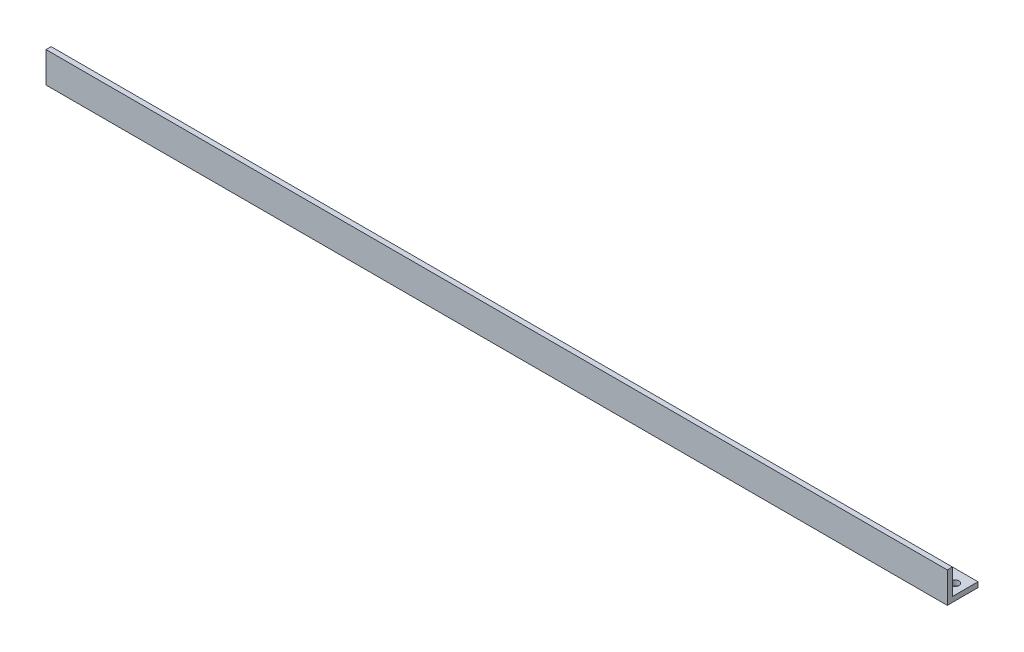
from build123d import *

# Parameters (mm, degrees)
BOSS_EXTRUDE1_DEPTH = 558.8
CUT_EXTRUDE1_REACH  = 5.175
SKETCH2_R           = 2.54


with BuildPart() as part:
    # Sketch1 → Boss-Extrude1 (new body)
    with BuildSketch(Plane(origin=(0, 0, 0), x_dir=(0, 0, -1), z_dir=(1, 0, 0))):
        Polygon((3.175, 3.175), (3.175, 19.05), (0, 19.05), (0, 0), (19.05, 0), (19.05, 3.175), align=None)
    extrude(amount=BOSS_EXTRUDE1_DEPTH)

    # Sketch2 → Cut-Extrude1 (cut, up to next)
    with BuildSketch(Plane(origin=(0, 3.175, 0), x_dir=(1, 0, 0), z_dir=(0, 1, 0)), mode=Mode.PRIVATE) as cut_extrude1_sk1:
        with Locations((552.45, 11.1125)):
            Circle(SKETCH2_R)
    cut_extrude1_tool1 = extrude(cut_extrude1_sk1.sketch, amount=-CUT_EXTRUDE1_REACH, mode=Mode.PRIVATE) & part.part
    add(cut_extrude1_tool1.solids().sort_by_distance((552.45, 3.175, -11.1125))[0], mode=Mode.SUBTRACT)
    # Sketch2 → Cut-Extrude1 (cut, up to next)
    with BuildSketch(Plane(origin=(0, 3.175, 0), x_dir=(1, 0, 0), z_dir=(0, 1, 0)), mode=Mode.PRIVATE) as cut_extrude1_sk2:
        with Locations((6.35, 11.1125)):
            Circle(SKETCH2_R)
    cut_extrude1_tool2 = extrude(cut_extrude1_sk2.sketch, amount=-CUT_EXTRUDE1_REACH, mode=Mode.PRIVATE) & part.part
    add(cut_extrude1_tool2.solids().sort_by_distance((6.35, 3.175, -11.1125))[0], mode=Mode.SUBTRACT)


solid = part.part
